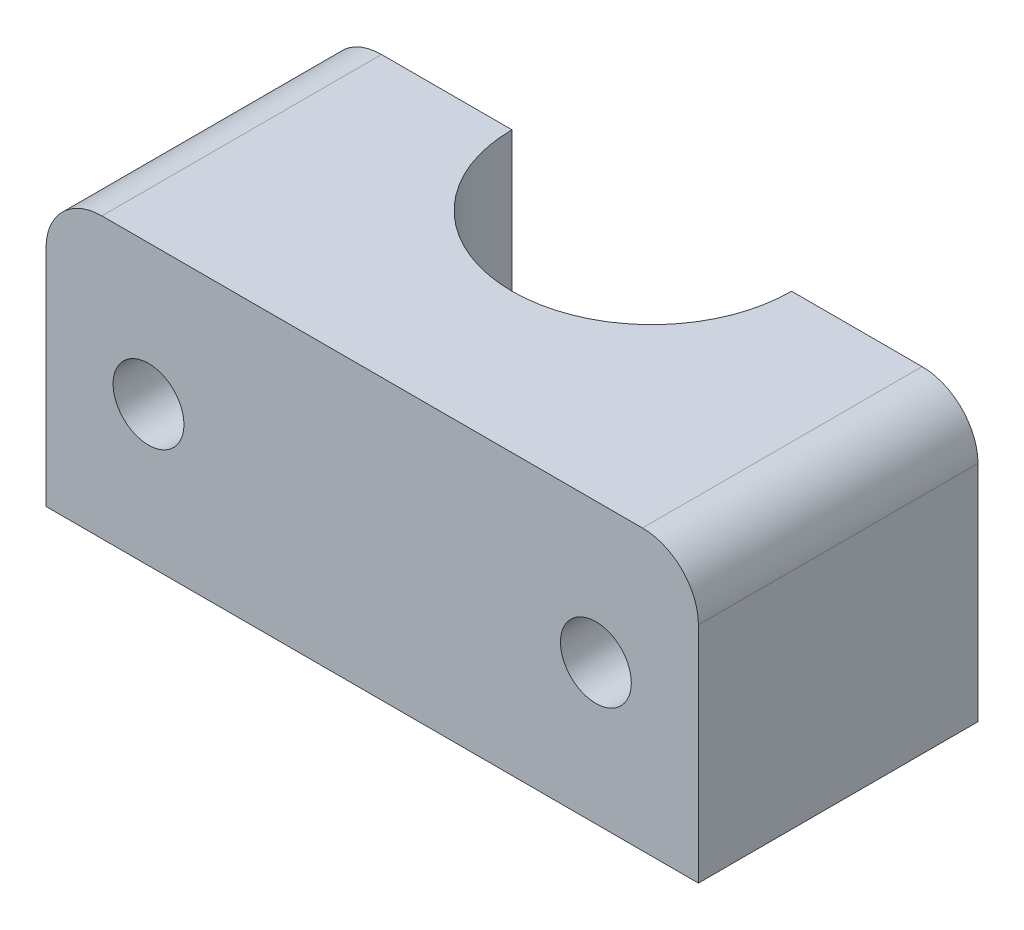
from build123d import *

# Parameters (mm, degrees)
SKETCH1_W           = 35
SKETCH1_H           = 15
BOSS_EXTRUDE1_DEPTH = 15
SKETCH2_R           = 1.9
CUT_EXTRUDE1_DEPTH  = 15
FILLET1_R           = 3
SKETCH3_R           = 7.5
CUT_EXTRUDE2_DEPTH  = 16


with BuildPart() as part:
    # Sketch1 → Boss-Extrude1 (new body)
    with BuildSketch(Plane.XY):
        Rectangle(SKETCH1_W, SKETCH1_H)
    extrude(amount=BOSS_EXTRUDE1_DEPTH)

    # Sketch2 → Cut-Extrude1 (cut)
    with BuildSketch(Plane.XY.offset(15)):
        with Locations((-12, 0)):
            Circle(SKETCH2_R)
        with Locations((12, 0)):
            Circle(SKETCH2_R)
    extrude(amount=-CUT_EXTRUDE1_DEPTH, mode=Mode.SUBTRACT)

    # Fillet1
    fillet1_edges = [part.edges().sort_by_distance(p)[0] for p in [
        (-17.5, 7.5, 7.5),
        (17.5, 7.5, 7.5),
    ]]
    fillet(fillet1_edges, radius=FILLET1_R)

    # Sketch3 → Cut-Extrude2 (cut, through all)
    with BuildSketch(Plane(origin=(0, 7.5, 0), x_dir=(1, 0, 0), z_dir=(0, 1, 0))):
        Circle(SKETCH3_R)
    extrude(amount=-CUT_EXTRUDE2_DEPTH, mode=Mode.SUBTRACT)


solid = part.part
